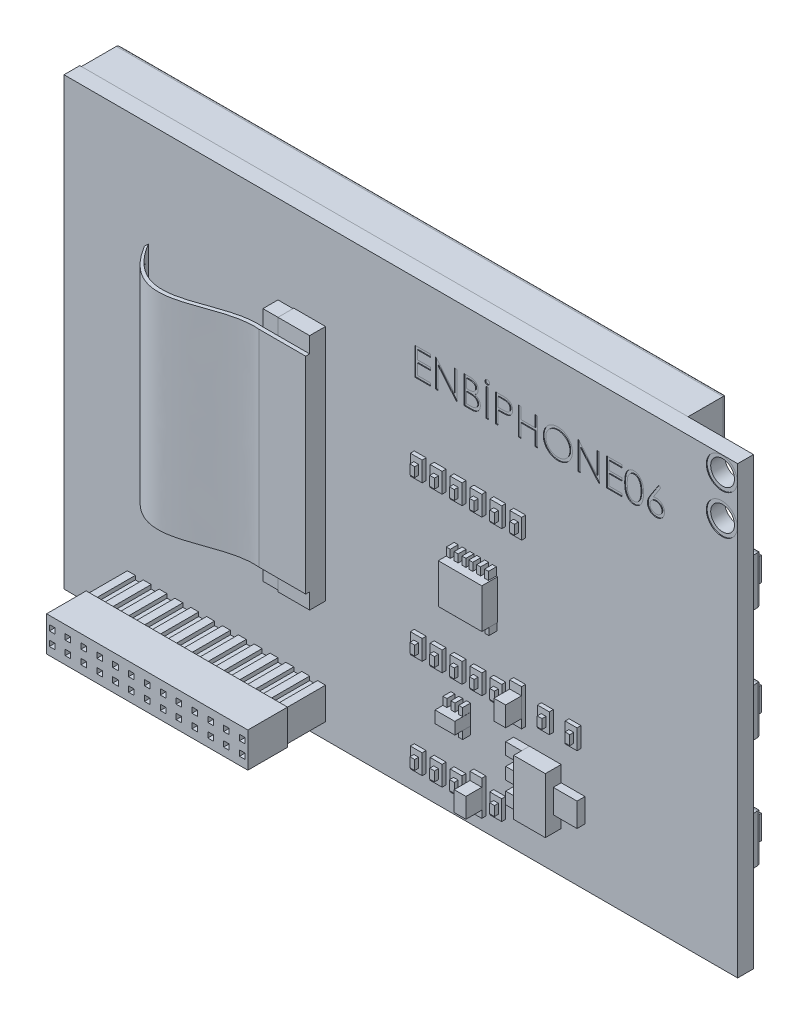
from build123d import *

# Parameters (mm, degrees)
SKETCH1_W            = 85.01
SKETCH1_H            = 56.21
BOSS_EXTRUDE1_DEPTH  = 2
SKETCH2_R            = 1.5
CUT_EXTRUDE1_DEPTH   = 2
SKETCH4_R            = 1.95
SKETCH4_R_2          = 1.5
CUT_EXTRUDE7_DEPTH   = 0.1
SKETCH5_R            = 1.95
SKETCH5_R_2          = 1.5
CUT_EXTRUDE8_DEPTH   = 0.1
SKETCH6_W            = 76.55
SKETCH6_H            = 53.88
BOSS_EXTRUDE2_DEPTH  = 5
SKETCH7_W            = 73.65
SKETCH7_H            = 50.98
CUT_EXTRUDE9_DEPTH   = 0.1
FILLET1_R            = 0.5
SKETCH8_W            = 3
SKETCH8_H            = 6
BOSS_EXTRUDE3_DEPTH  = 2
FILLET2_R            = 0.5
SKETCH9_W            = 1
SKETCH9_H            = 3
BOSS_EXTRUDE4_DEPTH  = 1
BOSS_EXTRUDE5_DEPTH  = 5
SKETCH11_W           = 25.4
SKETCH11_H           = 4.4
SKETCH11_W_2         = 0.7
SKETCH11_H_2         = 0.7
BOSS_EXTRUDE6_DEPTH  = 5
SKETCH13_W           = 1.5
SKETCH13_H           = 2.5
SKETCH13_H_2         = 4.4
SKETCH13_H_3         = 4.616877195
BOSS_EXTRUDE7_DEPTH  = 0.5
SKETCH16_W           = 0.6
SKETCH16_H           = 1.2
BOSS_EXTRUDE8_DEPTH  = 0.5
SKETCH17_W           = 1.48
SKETCH17_H           = 2.5
BOSS_EXTRUDE9_DEPTH  = 2
SKETCH19_W           = 4
SKETCH19_H           = 7
SKETCH19_W_2         = 2.5
SKETCH19_H_2         = 1.5
SKETCH19_W_3         = 5.5
SKETCH19_H_3         = 5
BOSS_EXTRUDE10_DEPTH = 2
SKETCH21_W           = 0.5
SKETCH21_H           = 1
SKETCH21_W_2         = 3
SKETCH21_H_2         = 3
SKETCH21_W_3         = 2
SKETCH21_H_3         = 1.5
BOSS_EXTRUDE12_DEPTH = 1
SKETCH22_W           = 4
SKETCH22_H           = 30
BOSS_EXTRUDE13_DEPTH = 2
SKETCH23_W           = 2
SKETCH23_H           = 29.8
BOSS_EXTRUDE14_DEPTH = 1.9
SKETCH25_W           = 5.9
SKETCH25_H           = 26
BOSS_EXTRUDE15_DEPTH = 0.5
BOSS_EXTRUDE16_DEPTH = 26
SKETCH28_W           = 0.314102564
SKETCH28_H           = 3.5
CUT_EXTRUDE10_DEPTH  = 0.1


with BuildPart() as part:
    # Sketch1 → Boss-Extrude1 (new body)
    with BuildSketch(Plane.XY):
        with Locations((42.505, 28.105)):
            Rectangle(SKETCH1_W, SKETCH1_H)
    extrude(amount=BOSS_EXTRUDE1_DEPTH)

    # Sketch2 → Cut-Extrude1 (cut)
    with BuildSketch(Plane.XY.offset(2)):
        with Locations((83.01, 54.21)):
            Circle(SKETCH2_R)
        with Locations((83.01, 49.21)):
            Circle(SKETCH2_R)
    extrude(amount=-CUT_EXTRUDE1_DEPTH, mode=Mode.SUBTRACT)

    # Sketch4 → Cut-Extrude7 (cut)
    with BuildSketch(Plane.XY.offset(2)):
        with Locations((83.01, 54.21)):
            Circle(SKETCH4_R)
        with Locations((83.01, 54.21)):
            Circle(SKETCH4_R_2, mode=Mode.SUBTRACT)
        with Locations((83.01, 49.21)):
            Circle(SKETCH4_R)
        with Locations((83.01, 49.21)):
            Circle(SKETCH4_R_2, mode=Mode.SUBTRACT)
    extrude(amount=-CUT_EXTRUDE7_DEPTH, mode=Mode.SUBTRACT)

    # Sketch5 → Cut-Extrude8 (cut)
    with BuildSketch(Plane(origin=(0, 0, 0), x_dir=(-1, 0, 0), z_dir=(0, 0, -1))):
        with Locations((-83.01, 54.21)):
            Circle(SKETCH5_R)
        with Locations((-83.01, 54.21)):
            Circle(SKETCH5_R_2, mode=Mode.SUBTRACT)
        with Locations((-83.01, 49.21)):
            Circle(SKETCH5_R)
        with Locations((-83.01, 49.21)):
            Circle(SKETCH5_R_2, mode=Mode.SUBTRACT)
    extrude(amount=-CUT_EXTRUDE8_DEPTH, mode=Mode.SUBTRACT)

    # Sketch6 → Boss-Extrude2 (add)
    with BuildSketch(Plane(origin=(0, 0, 0), x_dir=(-1, 0, 0), z_dir=(0, 0, -1))):
        with Locations((-38.375, 29.17)):
            Rectangle(SKETCH6_W, SKETCH6_H)
    extrude(amount=BOSS_EXTRUDE2_DEPTH)

    # Sketch7 → Cut-Extrude9 (cut)
    with BuildSketch(Plane(origin=(0, 0, -5), x_dir=(-1, 0, 0), z_dir=(0, 0, -1))):
        with Locations((-38.325, 29.22)):
            Rectangle(SKETCH7_W, SKETCH7_H)
    extrude(amount=-CUT_EXTRUDE9_DEPTH, mode=Mode.SUBTRACT)

    # Fillet1
    fillet1_edges = [part.edges().sort_by_distance(p)[0] for p in [
        (38.375, 56.11, -5),
        (76.65, 29.17, -5),
        (38.375, 2.23, -5),
        (0.1, 29.17, -5),
    ]]
    fillet(fillet1_edges, radius=FILLET1_R)

    # Sketch8 → Boss-Extrude3 (add)
    with BuildSketch(Plane(origin=(0, 0, 0), x_dir=(-1, 0, 0), z_dir=(0, 0, -1))):
        with Locations((-82.51, 13)):
            Rectangle(SKETCH8_W, SKETCH8_H)
        with Locations((-82.51, 27)):
            Rectangle(SKETCH8_W, SKETCH8_H)
        with Locations((-82.51, 41.21)):
            Rectangle(SKETCH8_W, SKETCH8_H)
    extrude(amount=BOSS_EXTRUDE3_DEPTH)

    # Fillet2
    fillet2_edges = [part.edges().sort_by_distance(p)[0] for p in [
        (81.01, 27, -2),
        (82.51, 30, -2),
        (84.01, 27, -2),
        (82.51, 24, -2),
        (82.51, 44.21, -2),
        (84.01, 41.21, -2),
        (82.51, 38.21, -2),
        (81.01, 41.21, -2),
        (84.01, 13, -2),
        (82.51, 10, -2),
        (81.01, 13, -2),
        (82.51, 16, -2),
    ]]
    fillet(fillet2_edges, radius=FILLET2_R)

    # Sketch9 → Boss-Extrude4 (add)
    with BuildSketch(Plane(origin=(0, 0, -2), x_dir=(-1, 0, 0), z_dir=(0, 0, -1))):
        with Locations((-82.51, 41.21)):
            Rectangle(SKETCH9_W, SKETCH9_H)
        with Locations((-82.51, 27)):
            Rectangle(SKETCH9_W, SKETCH9_H)
        with Locations((-82.51, 13)):
            Rectangle(SKETCH9_W, SKETCH9_H)
    extrude(amount=BOSS_EXTRUDE4_DEPTH)

    # Sketch10 → Boss-Extrude5 (add)
    with BuildSketch(Plane.XY.offset(2)):
        Polygon((8, 2), (8, 6), (9, 6), (9, 5.5), (10, 5.5), (10, 6), (11, 6), (11, 5.5), (12, 5.5), (12, 6), (13, 6), (13, 5.5), (14, 5.5), (14, 6), (15, 6), (15, 5.5), (16, 5.5), (16, 6), (17, 6), (17, 5.5), (18, 5.5), (18, 6), (19, 6), (19, 5.5), (20, 5.5), (20, 6), (21, 6), (21, 5.5), (22, 5.5), (22, 6), (23, 6), (23, 5.5), (24, 5.5), (24, 6), (25, 6), (25, 5.5), (26, 5.5), (26, 6), (27, 6), (27, 5.5), (28, 5.5), (28, 6), (29, 6), (29, 5.5), (30, 5.5), (30, 6), (31, 6), (31, 5.5), (32, 5.5), (32, 6), (33, 6), (33, 2), (32, 2), (32, 2.5), (31, 2.5), (31, 2), (30, 2), (30, 2.5), (29, 2.5), (29, 2), (28, 2), (28, 2.5), (27, 2.5), (27, 2), (26, 2), (26, 2.5), (25, 2.5), (25, 2), (24, 2), (24, 2.5), (23, 2.5), (23, 2), (22, 2), (22, 2.5), (21, 2.5), (21, 2), (20, 2), (20, 2.5), (19, 2.5), (19, 2), (18, 2), (18, 2.5), (17, 2.5), (17, 2), (16, 2), (16, 2.5), (15, 2.5), (15, 2), (14, 2), (14, 2.5), (13, 2.5), (13, 2), (12, 2), (12, 2.5), (11, 2.5), (11, 2), (10, 2), (10, 2.5), (9, 2.5), (9, 2), align=None)
    extrude(amount=BOSS_EXTRUDE5_DEPTH)

    # Sketch11 → Boss-Extrude6 (add)
    with BuildSketch(Plane.XY.offset(7)):
        with Locations((20.5, 4)):
            Rectangle(SKETCH11_W, SKETCH11_H)
        with Locations((8.5, 4.85)):
            Rectangle(SKETCH11_W_2, SKETCH11_H_2, mode=Mode.SUBTRACT)
        with Locations((10.5, 4.85)):
            Rectangle(SKETCH11_W_2, SKETCH11_H_2, mode=Mode.SUBTRACT)
        with Locations((32.5, 3.15)):
            Rectangle(SKETCH11_W_2, SKETCH11_H_2, mode=Mode.SUBTRACT)
        with Locations((12.5, 4.85)):
            Rectangle(SKETCH11_W_2, SKETCH11_H_2, mode=Mode.SUBTRACT)
        with Locations((14.5, 4.85)):
            Rectangle(SKETCH11_W_2, SKETCH11_H_2, mode=Mode.SUBTRACT)
        with Locations((16.5, 4.85)):
            Rectangle(SKETCH11_W_2, SKETCH11_H_2, mode=Mode.SUBTRACT)
        with Locations((18.5, 4.85)):
            Rectangle(SKETCH11_W_2, SKETCH11_H_2, mode=Mode.SUBTRACT)
        with Locations((30.5, 3.15)):
            Rectangle(SKETCH11_W_2, SKETCH11_H_2, mode=Mode.SUBTRACT)
        with Locations((20.5, 4.85)):
            Rectangle(SKETCH11_W_2, SKETCH11_H_2, mode=Mode.SUBTRACT)
        with Locations((22.5, 4.85)):
            Rectangle(SKETCH11_W_2, SKETCH11_H_2, mode=Mode.SUBTRACT)
        with Locations((24.5, 4.85)):
            Rectangle(SKETCH11_W_2, SKETCH11_H_2, mode=Mode.SUBTRACT)
        with Locations((26.5, 4.85)):
            Rectangle(SKETCH11_W_2, SKETCH11_H_2, mode=Mode.SUBTRACT)
        with Locations((28.5, 3.15)):
            Rectangle(SKETCH11_W_2, SKETCH11_H_2, mode=Mode.SUBTRACT)
        with Locations((28.5, 4.85)):
            Rectangle(SKETCH11_W_2, SKETCH11_H_2, mode=Mode.SUBTRACT)
        with Locations((30.5, 4.85)):
            Rectangle(SKETCH11_W_2, SKETCH11_H_2, mode=Mode.SUBTRACT)
        with Locations((32.5, 4.85)):
            Rectangle(SKETCH11_W_2, SKETCH11_H_2, mode=Mode.SUBTRACT)
        with Locations((26.5, 3.15)):
            Rectangle(SKETCH11_W_2, SKETCH11_H_2, mode=Mode.SUBTRACT)
        with Locations((24.5, 3.15)):
            Rectangle(SKETCH11_W_2, SKETCH11_H_2, mode=Mode.SUBTRACT)
        with Locations((22.5, 3.15)):
            Rectangle(SKETCH11_W_2, SKETCH11_H_2, mode=Mode.SUBTRACT)
        with Locations((20.5, 3.15)):
            Rectangle(SKETCH11_W_2, SKETCH11_H_2, mode=Mode.SUBTRACT)
        with Locations((18.5, 3.15)):
            Rectangle(SKETCH11_W_2, SKETCH11_H_2, mode=Mode.SUBTRACT)
        with Locations((16.5, 3.15)):
            Rectangle(SKETCH11_W_2, SKETCH11_H_2, mode=Mode.SUBTRACT)
        with Locations((14.5, 3.15)):
            Rectangle(SKETCH11_W_2, SKETCH11_H_2, mode=Mode.SUBTRACT)
        with Locations((12.5, 3.15)):
            Rectangle(SKETCH11_W_2, SKETCH11_H_2, mode=Mode.SUBTRACT)
        with Locations((10.5, 3.15)):
            Rectangle(SKETCH11_W_2, SKETCH11_H_2, mode=Mode.SUBTRACT)
        with Locations((8.5, 3.15)):
            Rectangle(SKETCH11_W_2, SKETCH11_H_2, mode=Mode.SUBTRACT)
    extrude(amount=BOSS_EXTRUDE6_DEPTH)

    # Sketch13 → Boss-Extrude7 (add)
    with BuildSketch(Plane.XY.offset(2)):
        with Locations((44.95, 3.95)):
            Rectangle(SKETCH13_W, SKETCH13_H)
        with Locations((52.477548998, 35.967092454)):
            Rectangle(SKETCH13_W, SKETCH13_H)
        with Locations((47.463774499, 3.95)):
            Rectangle(SKETCH13_W, SKETCH13_H)
        with Locations((49.977548998, 3.95)):
            Rectangle(SKETCH13_W, SKETCH13_H)
        with Locations((52.477548998, 4)):
            Rectangle(SKETCH13_W, SKETCH13_H_2)
        with Locations((54.977548998, 3.95)):
            Rectangle(SKETCH13_W, SKETCH13_H)
        with Locations((49.977548998, 16.45)):
            Rectangle(SKETCH13_W, SKETCH13_H)
        with Locations((47.463774499, 16.45)):
            Rectangle(SKETCH13_W, SKETCH13_H)
        with Locations((44.95, 16.45)):
            Rectangle(SKETCH13_W, SKETCH13_H)
        with Locations((52.477548998, 16.45)):
            Rectangle(SKETCH13_W, SKETCH13_H)
        with Locations((54.991323497, 16.45)):
            Rectangle(SKETCH13_W, SKETCH13_H)
        with Locations((57.491323497, 16.391561403)):
            Rectangle(SKETCH13_W, SKETCH13_H_3)
        with Locations((60.991323497, 16.45)):
            Rectangle(SKETCH13_W, SKETCH13_H)
        with Locations((64.491323497, 16.45)):
            Rectangle(SKETCH13_W, SKETCH13_H)
        with Locations((54.991323497, 35.967092454)):
            Rectangle(SKETCH13_W, SKETCH13_H)
        with Locations((47.463774499, 35.967092454)):
            Rectangle(SKETCH13_W, SKETCH13_H)
        with Locations((49.977548998, 35.967092454)):
            Rectangle(SKETCH13_W, SKETCH13_H)
        with Locations((44.95, 35.95)):
            Rectangle(SKETCH13_W, SKETCH13_H)
        with Locations((57.505097996, 35.967092454)):
            Rectangle(SKETCH13_W, SKETCH13_H)
    extrude(amount=BOSS_EXTRUDE7_DEPTH)

    # Sketch16 → Boss-Extrude8 (add)
    with BuildSketch(Plane.XY.offset(2.5)):
        with Locations((44.95, 3.9)):
            Rectangle(SKETCH16_W, SKETCH16_H)
        with Locations((47.45, 3.9)):
            Rectangle(SKETCH16_W, SKETCH16_H)
        with Locations((49.95, 3.9)):
            Rectangle(SKETCH16_W, SKETCH16_H)
        with Locations((55.020165357, 16.4)):
            Rectangle(SKETCH16_W, SKETCH16_H)
        with Locations((44.95, 16.4)):
            Rectangle(SKETCH16_W, SKETCH16_H)
        with Locations((49.95, 16.4)):
            Rectangle(SKETCH16_W, SKETCH16_H)
        with Locations((55.020165357, 3.9)):
            Rectangle(SKETCH16_W, SKETCH16_H)
        with Locations((47.45, 16.4)):
            Rectangle(SKETCH16_W, SKETCH16_H)
        with Locations((52.45, 16.4)):
            Rectangle(SKETCH16_W, SKETCH16_H)
        with Locations((61.020165357, 16.4)):
            Rectangle(SKETCH16_W, SKETCH16_H)
        with Locations((64.520165357, 16.4)):
            Rectangle(SKETCH16_W, SKETCH16_H)
        with Locations((55.020165357, 35.9)):
            Rectangle(SKETCH16_W, SKETCH16_H)
        with Locations((52.45, 35.9)):
            Rectangle(SKETCH16_W, SKETCH16_H)
        with Locations((44.95, 35.9)):
            Rectangle(SKETCH16_W, SKETCH16_H)
        with Locations((49.95, 35.9)):
            Rectangle(SKETCH16_W, SKETCH16_H)
        with Locations((47.45, 35.9)):
            Rectangle(SKETCH16_W, SKETCH16_H)
        with Locations((57.533939856, 35.9)):
            Rectangle(SKETCH16_W, SKETCH16_H)
    extrude(amount=BOSS_EXTRUDE8_DEPTH)

    # Sketch17 → Boss-Extrude9 (add)
    with BuildSketch(Plane.XY.offset(2.5)):
        with Locations((52.477548998, 3.95)):
            Rectangle(SKETCH17_W, SKETCH17_H)
        with Locations((57.491323497, 16.45)):
            Rectangle(SKETCH17_W, SKETCH17_H)
    extrude(amount=BOSS_EXTRUDE9_DEPTH)

    # Sketch19 → Boss-Extrude10 (add)
    with BuildSketch(Plane.XY.offset(2)):
        with Locations((60.741323497, 8.7)):
            Rectangle(SKETCH19_W, SKETCH19_H)
        with Locations((50.06634195, 11.45)):
            Rectangle(SKETCH19_W_2, SKETCH19_H_2)
        with Locations((51.977548998, 26.217092454)):
            Rectangle(SKETCH19_W_3, SKETCH19_H_3)
    extrude(amount=BOSS_EXTRUDE10_DEPTH)

    # Sketch21 → Boss-Extrude12 (add)
    with BuildSketch(Plane.XY.offset(2)):
        with Locations((49.07634195, 12.7)):
            Rectangle(SKETCH21_W, SKETCH21_H)
        with Locations((50.07634195, 12.7)):
            Rectangle(SKETCH21_W, SKETCH21_H)
        with Locations((51.05634195, 12.7)):
            Rectangle(SKETCH21_W, SKETCH21_H)
        with Locations((51.05634195, 10.2)):
            Rectangle(SKETCH21_W, SKETCH21_H)
        with Locations((50.07634195, 10.2)):
            Rectangle(SKETCH21_W, SKETCH21_H)
        with Locations((49.07634195, 10.2)):
            Rectangle(SKETCH21_W, SKETCH21_H)
        with Locations((50.487548998, 29.217092454)):
            Rectangle(SKETCH21_W, SKETCH21_H)
        with Locations((49.487548998, 29.217092454)):
            Rectangle(SKETCH21_W, SKETCH21_H)
        with Locations((51.467548998, 29.217092454)):
            Rectangle(SKETCH21_W, SKETCH21_H)
        with Locations((53.33135448, 29.217092454)):
            Rectangle(SKETCH21_W, SKETCH21_H)
        with Locations((52.33135448, 29.217092454)):
            Rectangle(SKETCH21_W, SKETCH21_H)
        with Locations((54.31135448, 29.217092454)):
            Rectangle(SKETCH21_W, SKETCH21_H)
        with Locations((51.521343836, 23.214974242)):
            Rectangle(SKETCH21_W, SKETCH21_H)
        with Locations((52.385149318, 23.214974242)):
            Rectangle(SKETCH21_W, SKETCH21_H)
        with Locations((53.385149318, 23.214974242)):
            Rectangle(SKETCH21_W, SKETCH21_H)
        with Locations((54.365149318, 23.214974242)):
            Rectangle(SKETCH21_W, SKETCH21_H)
        with Locations((50.541343836, 23.214974242)):
            Rectangle(SKETCH21_W, SKETCH21_H)
        with Locations((49.541343836, 23.214974242)):
            Rectangle(SKETCH21_W, SKETCH21_H)
        with Locations((64.241323497, 8.7)):
            Rectangle(SKETCH21_W_2, SKETCH21_H_2)
        with Locations((57.741323497, 11.44)):
            Rectangle(SKETCH21_W_3, SKETCH21_H_3)
        with Locations((57.741323497, 8.74)):
            Rectangle(SKETCH21_W_3, SKETCH21_H_3)
        with Locations((57.741323497, 6.04)):
            Rectangle(SKETCH21_W_3, SKETCH21_H_3)
    extrude(amount=BOSS_EXTRUDE12_DEPTH)

    # Sketch22 → Boss-Extrude13 (add)
    with BuildSketch(Plane.XY.offset(2)):
        with Locations((31, 30.2)):
            Rectangle(SKETCH22_W, SKETCH22_H)
    extrude(amount=BOSS_EXTRUDE13_DEPTH)

    # Sketch23 → Boss-Extrude14 (add)
    with BuildSketch(Plane.XY.offset(2)):
        with Locations((28, 30.2)):
            Rectangle(SKETCH23_W, SKETCH23_H)
    extrude(amount=BOSS_EXTRUDE14_DEPTH)

    # Sketch25 → Boss-Extrude15 (add)
    with BuildSketch(Plane.XY.offset(4)):
        with Locations((30.05, 30.2)):
            Rectangle(SKETCH25_W, SKETCH25_H)
    extrude(amount=BOSS_EXTRUDE15_DEPTH)

    # Sketch26 → Boss-Extrude16 (add)
    with BuildSketch(Plane(origin=(0, 43.2, 0), x_dir=(1, 0, 0), z_dir=(0, 1, 0))):
        with BuildLine():
            Line((27.1, -4.5), (27.1, -4))
            add(Edge.make_bspline(
                [(27.1, -4), (21.203971865, -3.448625786), (15.858377482, -10.525644499), (10.802416979, -2.164049527)],
                knots=[0, 0, 0, 0, 1, 1, 1, 1], degree=3))
            Line((10.802416979, -2.164049527), (10.802416979, -2.664049527))
            add(Edge.make_bspline(
                [(27.1, -4.5), (21.203971865, -3.948625786), (15.858377482, -11.025644499), (10.802416979, -2.664049527)],
                knots=[0, 0, 0, 0, 1, 1, 1, 1], degree=3))
        make_face()
    extrude(amount=-BOSS_EXTRUDE16_DEPTH)

    # Sketch28 → Cut-Extrude10 (cut)
    with BuildSketch(Plane.XY.offset(2)):
        Polygon((44.281025042, 48.793626853), (46.255384016, 48.793626853), (46.255384016, 48.434652494), (44.595127606, 48.434652494), (44.595127606, 47.357729418), (46.255384016, 47.357729418), (46.255384016, 46.998755059), (44.595127606, 46.998755059), (44.595127606, 45.652601212), (46.255384016, 45.652601212), (46.255384016, 45.293626853), (44.281025042, 45.293626853), align=None)
        Polygon((46.883589144, 45.293626853), (46.883589144, 48.793626853), (46.949494593, 48.793626853), (49.261794272, 46.038919321), (49.261794272, 48.793626853), (49.575896837, 48.793626853), (49.575896837, 45.293626853), (49.504382413, 45.293626853), (47.197691708, 48.042024289), (47.197691708, 45.293626853), align=None)
        with BuildLine():
            Line((50.473332734, 48.793626853), (51.156225362, 48.793626853))
            add(Edge.make_bspline(
                [(51.156225362, 48.793626853), (51.18965384, 48.793451103), (51.254446551, 48.793110455), (51.348665993, 48.787827324), (51.436914803, 48.780623654), (51.519218576, 48.769193561), (51.595539278, 48.755401784), (51.666106915, 48.738699968), (51.730697087, 48.718673354), (51.807809824, 48.686827073), (51.895730485, 48.639503905), (51.990928877, 48.56957534), (52.072333117, 48.484042877), (52.142519434, 48.387560221), (52.198320554, 48.281424449), (52.238689851, 48.168165261), (52.264247726, 48.049243519), (52.26687616, 47.967600341), (52.268204529, 47.926339193)],
                knots=[0, 0, 0, 0, 0.00010027, 0.000194349, 0.000283026, 0.000365821, 0.000443519, 0.000515622, 0.000583254, 0.00064614, 0.000765662, 0.000881909, 0.000998927, 0.001118415, 0.001238844, 0.00135727, 0.001478274, 0.001601912, 0.001601912, 0.001601912, 0.001601912], degree=3))
            add(Edge.make_bspline(
                [(52.268204529, 47.926339193), (52.26711131, 47.887686638), (52.264963033, 47.81173072), (52.244420274, 47.700636611), (52.212259605, 47.594885392), (52.167554356, 47.494863007), (52.10945236, 47.402829394), (52.040594041, 47.318042128), (51.957517239, 47.244091071), (51.895273999, 47.202748168), (51.863657253, 47.181747847)],
                knots=[0, 0, 0, 0, 0.000115857, 0.00022767, 0.000337672, 0.000446877, 0.000555233, 0.000663318, 0.000773539, 0.000887324, 0.000887324, 0.000887324, 0.000887324], degree=3))
            add(Edge.make_bspline(
                [(51.863657253, 47.181747847), (51.903417681, 47.166482848), (51.979489228, 47.137277124), (52.084175241, 47.08564166), (52.174370086, 47.029479549), (52.250767232, 46.968147699), (52.316104886, 46.902038888), (52.373157828, 46.830183774), (52.421839202, 46.751645016), (52.463552126, 46.667241481), (52.496100882, 46.577835013), (52.520476786, 46.484264236), (52.534444235, 46.386864681), (52.536431877, 46.320579302), (52.537435298, 46.287116437)],
                knots=[0, 0, 0, 0, 0.000127722, 0.000244363, 0.000349599, 0.000445847, 0.000537565, 0.000627901, 0.000720503, 0.000814257, 0.000909859, 0.001005428, 0.001103887, 0.001204268, 0.001204268, 0.001204268, 0.001204268], degree=3))
            add(Edge.make_bspline(
                [(52.537435298, 46.287116437), (52.536458452, 46.252949565), (52.53453648, 46.185725287), (52.520356508, 46.086970152), (52.496347401, 45.992595205), (52.463276255, 45.901990023), (52.42011394, 45.815329888), (52.367585976, 45.732516624), (52.304954412, 45.654382294), (52.234891543, 45.580058671), (52.155629398, 45.513230883), (52.070113643, 45.453715176), (51.977267323, 45.404769114), (51.878615329, 45.363653093), (51.773051013, 45.332245894), (51.661048406, 45.310273321), (51.542704104, 45.295468284), (51.461494353, 45.294251079), (51.419847157, 45.293626853)],
                knots=[0, 0, 0, 0, 0.000102481, 0.000201635, 0.000298562, 0.000394165, 0.000490425, 0.000588455, 0.000687769, 0.000790423, 0.000894381, 0.000998232, 0.001102369, 0.001208616, 0.001318415, 0.001432129, 0.001550749, 0.00167562, 0.00167562, 0.00167562, 0.00167562], degree=3))
            Line((51.419847157, 45.293626853), (50.473332734, 45.293626853))
            Line((50.473332734, 45.293626853), (50.473332734, 48.793626853))
        make_face()
        with BuildLine():
            Line((50.787435298, 48.434652494), (50.787435298, 47.312857623))
            Line((50.787435298, 47.312857623), (50.998472958, 47.312857623))
            add(Edge.make_bspline(
                [(50.998472958, 47.312857623), (51.029321754, 47.313257546), (51.088927913, 47.314030278), (51.175247809, 47.316243795), (51.255372828, 47.322441839), (51.329164661, 47.328638101), (51.396507105, 47.338712689), (51.457250966, 47.350704812), (51.512349563, 47.363387717), (51.575889109, 47.384957204), (51.647962057, 47.416834879), (51.724795161, 47.466306715), (51.792529631, 47.525231068), (51.849726819, 47.59322203), (51.896538289, 47.668088216), (51.929052004, 47.748635096), (51.951099288, 47.832855228), (51.95309082, 47.890673481), (51.954101965, 47.920029097)],
                knots=[0, 0, 0, 0, 9.2559e-05, 0.000178842, 0.000258967, 0.000333616, 0.000400942, 0.000463093, 0.000519379, 0.000570374, 0.000664201, 0.000755025, 0.000843472, 0.000932526, 0.001020669, 0.001107124, 0.001192318, 0.001280185, 0.001280185, 0.001280185, 0.001280185], degree=3))
            add(Edge.make_bspline(
                [(51.954101965, 47.920029097), (51.953575785, 47.939454869), (51.952543625, 47.977560641), (51.944090322, 48.033109995), (51.929722748, 48.085353747), (51.911268454, 48.135007858), (51.885479766, 48.180519708), (51.855116302, 48.223462904), (51.818430612, 48.262375022), (51.776673299, 48.29874452), (51.728664677, 48.330989048), (51.674433385, 48.359229811), (51.613245708, 48.381970588), (51.546132853, 48.40188674), (51.472061765, 48.415875034), (51.391887212, 48.427528422), (51.304952493, 48.433461164), (51.24480739, 48.434246527), (51.213717349, 48.434652494)],
                knots=[0, 0, 0, 0, 5.8261e-05, 0.000114285, 0.000168029, 0.000220632, 0.000272728, 0.000324483, 0.000378062, 0.000432741, 0.000490301, 0.000551137, 0.000615721, 0.000685833, 0.000760908, 0.00084162, 0.000928788, 0.00102206, 0.00102206, 0.00102206, 0.00102206], degree=3))
            Line((51.213717349, 48.434652494), (50.787435298, 48.434652494))
        make_face(mode=Mode.SUBTRACT)
        with BuildLine():
            Line((50.787435298, 46.953883264), (50.787435298, 45.652601212))
            Line((50.787435298, 45.652601212), (51.234751003, 45.652601212))
            add(Edge.make_bspline(
                [(51.234751003, 45.652601212), (51.266769929, 45.65298496), (51.328482188, 45.653724582), (51.417583418, 45.656139137), (51.500166522, 45.661631413), (51.575854657, 45.670277262), (51.64546511, 45.679655711), (51.708162813, 45.692266992), (51.764456006, 45.706715953), (51.829730314, 45.729050125), (51.903233822, 45.763746596), (51.982444679, 45.816060822), (52.052870897, 45.87838413), (52.112676156, 45.950515044), (52.161689145, 46.028946371), (52.1973446, 46.112091721), (52.219335457, 46.198577249), (52.221997626, 46.257543961), (52.223332734, 46.287116437)],
                knots=[0, 0, 0, 0, 9.6064e-05, 0.000185151, 0.000267373, 0.000344257, 0.000413665, 0.000478015, 0.000536005, 0.000587888, 0.000684801, 0.000778918, 0.000871787, 0.000965866, 0.001059062, 0.00114827, 0.001236355, 0.001324974, 0.001324974, 0.001324974, 0.001324974], degree=3))
            add(Edge.make_bspline(
                [(52.223332734, 46.287116437), (52.22305663, 46.305609777), (52.222508875, 46.342298159), (52.21424826, 46.396213978), (52.20223439, 46.448439852), (52.186702956, 46.499117592), (52.164083489, 46.547330968), (52.137676944, 46.594033528), (52.106715542, 46.639287007), (52.058471376, 46.696499261), (51.988299392, 46.762416274), (51.888592616, 46.826953776), (51.775220318, 46.879001583), (51.692992825, 46.901101059), (51.650516228, 46.912517078)],
                knots=[0, 0, 0, 0, 5.5429e-05, 0.000109963, 0.000163198, 0.000216191, 0.000268588, 0.000322593, 0.000377046, 0.000432793, 0.000546889, 0.000664343, 0.000787646, 0.000919405, 0.000919405, 0.000919405, 0.000919405], degree=3))
            add(Edge.make_bspline(
                [(51.650516228, 46.912517078), (51.633487132, 46.915972162), (51.596564539, 46.923463496), (51.536356959, 46.9313712), (51.46762109, 46.93841626), (51.390198213, 46.943627417), (51.303990372, 46.949013961), (51.208813453, 46.951108782), (51.105056138, 46.953608042), (51.033063766, 46.953789176), (50.995668471, 46.953883264)],
                knots=[0, 0, 0, 0, 5.2115e-05, 0.000112995, 0.000182062, 0.000259389, 0.000345767, 0.00044116, 0.000544948, 0.000657129, 0.000657129, 0.000657129, 0.000657129], degree=3))
            Line((50.995668471, 46.953883264), (50.787435298, 46.953883264))
        make_face(mode=Mode.SUBTRACT)
        with Locations((53.412435298, 47.043626853)):
            Rectangle(SKETCH28_W, SKETCH28_H)
        with BuildLine():
            add(Edge.make_bspline(
                [(53.412435298, 49.601319161), (53.431916304, 49.600144348), (53.470106538, 49.597841263), (53.525586444, 49.582471089), (53.575163638, 49.553815021), (53.619931675, 49.517148871), (53.656597825, 49.472380835), (53.685253893, 49.422803641), (53.700624067, 49.367323734), (53.702927151, 49.3291335), (53.704101965, 49.309652494)],
                knots=[0, 0, 0, 0, 5.8463e-05, 0.000114609, 0.000170791, 0.000229052, 0.000287312, 0.000343494, 0.000399641, 0.000458104, 0.000458104, 0.000458104, 0.000458104], degree=3))
            add(Edge.make_bspline(
                [(53.704101965, 49.309652494), (53.702965528, 49.290157803), (53.700750776, 49.252165425), (53.684913016, 49.1968904), (53.656854091, 49.14700403), (53.619863131, 49.102247606), (53.575394764, 49.065281557), (53.525244636, 49.037894454), (53.470266111, 49.021192917), (53.431948036, 49.019067934), (53.412435298, 49.017985828)],
                knots=[0, 0, 0, 0, 5.8463e-05, 0.000113936, 0.000170731, 0.000228992, 0.000287252, 0.000343096, 0.000399439, 0.000457902, 0.000457902, 0.000457902, 0.000457902], degree=3))
            add(Edge.make_bspline(
                [(53.412435298, 49.017985828), (53.392908501, 49.019028758), (53.354787078, 49.02106483), (53.300013719, 49.038237094), (53.249558065, 49.065024111), (53.205098347, 49.102315543), (53.167806914, 49.146775261), (53.141019898, 49.197230915), (53.123847633, 49.252004274), (53.121811561, 49.290125697), (53.120768631, 49.309652494)],
                knots=[0, 0, 0, 0, 5.8463e-05, 0.000114135, 0.000170596, 0.000228856, 0.000287117, 0.000343578, 0.00039925, 0.000457713, 0.000457713, 0.000457713, 0.000457713], degree=3))
            add(Edge.make_bspline(
                [(53.120768631, 49.309652494), (53.121850738, 49.329165232), (53.12397572, 49.367483307), (53.140677258, 49.422461832), (53.168064361, 49.472611961), (53.20503041, 49.517080328), (53.249786833, 49.554071287), (53.299673203, 49.582130213), (53.354948229, 49.597967972), (53.392940607, 49.600182725), (53.412435298, 49.601319161)],
                knots=[0, 0, 0, 0, 5.8463e-05, 0.000114806, 0.00017065, 0.000228911, 0.000287171, 0.000343966, 0.000399439, 0.000457902, 0.000457902, 0.000457902, 0.000457902], degree=3))
        make_face()
        with BuildLine():
            Line((54.466922478, 48.793626853), (55.153320715, 48.793626853))
            add(Edge.make_bspline(
                [(55.153320715, 48.793626853), (55.200531621, 48.793574957), (55.290989814, 48.793475522), (55.420704869, 48.790460776), (55.538514601, 48.786434084), (55.644164982, 48.780852191), (55.73798108, 48.7742556), (55.81953838, 48.765003561), (55.889477936, 48.755343265), (55.931384385, 48.745521859), (55.950496195, 48.741042719)],
                knots=[0, 0, 0, 0, 0.000141628, 0.000271366, 0.00038923, 0.000495248, 0.00058876, 0.000671296, 0.000741499, 0.00080036, 0.00080036, 0.00080036, 0.00080036], degree=3))
            add(Edge.make_bspline(
                [(55.950496195, 48.741042719), (55.974689729, 48.734420769), (56.022506706, 48.721332907), (56.09140775, 48.695119184), (56.156961595, 48.664037019), (56.219393154, 48.628613079), (56.277935237, 48.587327515), (56.333461278, 48.541853897), (56.385481258, 48.491142328), (56.43370265, 48.435761588), (56.477987447, 48.376641379), (56.51611713, 48.312899149), (56.548044357, 48.245607845), (56.575427629, 48.174814274), (56.595136083, 48.099923951), (56.609982983, 48.021457238), (56.61940661, 47.939422548), (56.620309172, 47.88336268), (56.620768631, 47.85482477)],
                knots=[0, 0, 0, 0, 7.5216e-05, 0.00014866, 0.000220794, 0.000292713, 0.000363707, 0.000435434, 0.000507823, 0.000581364, 0.000655543, 0.000729131, 0.000803767, 0.000878771, 0.000956497, 0.001035702, 0.001118238, 0.001203821, 0.001203821, 0.001203821, 0.001203821], degree=3))
            add(Edge.make_bspline(
                [(56.620768631, 47.85482477), (56.620347207, 47.826046993), (56.619522661, 47.769741329), (56.609626375, 47.687368541), (56.596296184, 47.608650151), (56.575799131, 47.533760701), (56.548953458, 47.46314493), (56.517461405, 47.395723698), (56.479477875, 47.332644026), (56.435833045, 47.273676909), (56.387281451, 47.218766996), (56.334028513, 47.168312202), (56.27628922, 47.122607863), (56.214247072, 47.08155152), (56.147297223, 47.04609524), (56.07645507, 47.014337935), (56.001104853, 46.987666875), (55.948962339, 46.973636813), (55.922451324, 46.966503456)],
                knots=[0, 0, 0, 0, 8.6284e-05, 0.00016882, 0.000248587, 0.000325638, 0.000401297, 0.000474998, 0.000548586, 0.000621785, 0.0006948, 0.0007682, 0.000841564, 0.000915458, 0.000991056, 0.00106858, 0.00114819, 0.001230532, 0.001230532, 0.001230532, 0.001230532], degree=3))
            add(Edge.make_bspline(
                [(55.922451324, 46.966503456), (55.90052399, 46.961840475), (55.852468962, 46.951621281), (55.77332624, 46.940212824), (55.681180854, 46.930475223), (55.576158574, 46.923174086), (55.458353669, 46.916923717), (55.327702412, 46.911955623), (55.183948335, 46.909225769), (55.083677091, 46.909084977), (55.031325522, 46.909011469)],
                knots=[0, 0, 0, 0, 6.7238e-05, 0.000147357, 0.000239727, 0.000345177, 0.000463135, 0.000593636, 0.000737393, 0.000894446, 0.000894446, 0.000894446, 0.000894446], degree=3))
            Line((55.031325522, 46.909011469), (54.781025042, 46.909011469))
            Line((54.781025042, 46.909011469), (54.781025042, 45.293626853))
            Line((54.781025042, 45.293626853), (54.466922478, 45.293626853))
            Line((54.466922478, 45.293626853), (54.466922478, 48.793626853))
        make_face()
        with BuildLine():
            Line((54.781025042, 48.434652494), (54.781025042, 47.267985828))
            Line((54.781025042, 47.267985828), (55.39380549, 47.260273488))
            add(Edge.make_bspline(
                [(55.39380549, 47.260273488), (55.423725416, 47.260258024), (55.481485216, 47.260228172), (55.564921439, 47.264213396), (55.642330727, 47.268813928), (55.713475302, 47.275549852), (55.778387237, 47.285071109), (55.837174765, 47.294682847), (55.889382048, 47.30858821), (55.95048125, 47.327311279), (56.018564598, 47.359243895), (56.092632146, 47.405593785), (56.155402732, 47.464674493), (56.209721029, 47.531102324), (56.252826907, 47.605001454), (56.284382899, 47.68407039), (56.302924057, 47.76749824), (56.30541025, 47.824586379), (56.306666067, 47.853422527)],
                knots=[0, 0, 0, 0, 8.9746e-05, 0.000173253, 0.000250533, 0.00032239, 0.000387534, 0.00044736, 0.000500926, 0.000549486, 0.000638903, 0.000725641, 0.000810488, 0.000896226, 0.000982324, 0.00106604, 0.001150757, 0.001237226, 0.001237226, 0.001237226, 0.001237226], degree=3))
            add(Edge.make_bspline(
                [(56.306666067, 47.853422527), (56.305403421, 47.88156104), (56.302893436, 47.937496922), (56.284237573, 48.019475683), (56.252888259, 48.097711387), (56.209431664, 48.170684472), (56.156690534, 48.236873276), (56.095391191, 48.294370404), (56.02567793, 48.340592106), (55.960829699, 48.370425388), (55.903228513, 48.388640663), (55.853196553, 48.401385504), (55.796705878, 48.41156111), (55.733738099, 48.419800613), (55.664781265, 48.426854074), (55.58924295, 48.431640051), (55.507409307, 48.434441508), (55.450598736, 48.434580463), (55.42114924, 48.434652494)],
                knots=[0, 0, 0, 0, 8.4371e-05, 0.000167719, 0.000250783, 0.000336277, 0.000421575, 0.000503926, 0.000587348, 0.000671427, 0.000717102, 0.000768457, 0.000826213, 0.000889178, 0.000958942, 0.001034123, 0.001116202, 0.001204546, 0.001204546, 0.001204546, 0.001204546], degree=3))
            Line((55.42114924, 48.434652494), (54.781025042, 48.434652494))
        make_face(mode=Mode.SUBTRACT)
        Polygon((57.338717349, 48.793626853), (57.652819913, 48.793626853), (57.652819913, 47.357729418), (59.447691708, 47.357729418), (59.447691708, 48.793626853), (59.761794272, 48.793626853), (59.761794272, 45.293626853), (59.447691708, 45.293626853), (59.447691708, 46.998755059), (57.652819913, 46.998755059), (57.652819913, 45.293626853), (57.338717349, 45.293626853), align=None)
        with BuildLine():
            add(Edge.make_bspline(
                [(62.297050683, 48.883370443), (62.361858789, 48.881728964), (62.489147256, 48.878504963), (62.676222153, 48.853825859), (62.854817249, 48.811130469), (63.026387387, 48.754267487), (63.188880364, 48.678413102), (63.343519256, 48.586727953), (63.48993613, 48.478251494), (63.626157512, 48.353822268), (63.750814462, 48.218438814), (63.860640348, 48.073960904), (63.952682642, 47.921262101), (64.028268429, 47.760801271), (64.087567039, 47.592941303), (64.128486083, 47.4167873), (64.154624233, 47.23348061), (64.15768001, 47.108453745), (64.15923017, 47.045029097)],
                knots=[0, 0, 0, 0, 0.000194393, 0.000381804, 0.00056479, 0.000744601, 0.000923091, 0.001101652, 0.001283106, 0.001468738, 0.001654324, 0.001834514, 0.002012231, 0.002188181, 0.002365797, 0.002545211, 0.002729936, 0.002920126, 0.002920126, 0.002920126, 0.002920126], degree=3))
            add(Edge.make_bspline(
                [(64.15923017, 47.045029097), (64.157680237, 46.982071651), (64.154625141, 46.85797523), (64.128456363, 46.675831786), (64.087415363, 46.50074109), (64.028819097, 46.332995437), (63.953593619, 46.172417873), (63.860938447, 46.019430919), (63.751797237, 45.873984421), (63.627590386, 45.737671756), (63.492189344, 45.612674285), (63.346959077, 45.503755409), (63.195165757, 45.410031285), (63.034856049, 45.335247611), (62.868156012, 45.27547569), (62.693573689, 45.23472306), (62.511927135, 45.208436017), (62.388056131, 45.205417501), (62.325095554, 45.203883264)],
                knots=[0, 0, 0, 0, 0.000188789, 0.000372126, 0.000550857, 0.00072758, 0.000904164, 0.001081881, 0.001263191, 0.001448823, 0.00163441, 0.001815159, 0.001992641, 0.002168591, 0.002344885, 0.002522934, 0.002705576, 0.002894365, 0.002894365, 0.002894365, 0.002894365], degree=3))
            add(Edge.make_bspline(
                [(62.325095554, 45.203883264), (62.261671235, 45.205432651), (62.13664502, 45.208486904), (61.953107984, 45.234668309), (61.77683024, 45.275609613), (61.608315889, 45.334119049), (61.44747096, 45.40973628), (61.293980877, 45.501940659), (61.14846173, 45.6113478), (61.012119983, 45.735514375), (60.887370785, 45.870685927), (60.778611409, 46.015520182), (60.686386296, 46.167175639), (60.611022963, 46.326073163), (60.551358504, 46.491444605), (60.510653686, 46.664393083), (60.484317734, 46.843932589), (60.481282887, 46.966175487), (60.47974299, 47.028202174)],
                knots=[0, 0, 0, 0, 0.00019019, 0.000374915, 0.000555011, 0.000732396, 0.00090898, 0.001087298, 0.001268608, 0.00145424, 0.001639827, 0.001819595, 0.001996712, 0.002171394, 0.002346367, 0.002523053, 0.002703612, 0.002889599, 0.002889599, 0.002889599, 0.002889599], degree=3))
            add(Edge.make_bspline(
                [(60.47974299, 47.028202174), (60.480277626, 47.069834843), (60.481340152, 47.152574967), (60.494131845, 47.275441567), (60.512693546, 47.396332225), (60.539295458, 47.514903172), (60.574087125, 47.630864157), (60.615139153, 47.74501492), (60.665278998, 47.856198644), (60.721959646, 47.964942035), (60.785221454, 48.069549941), (60.855097204, 48.168429524), (60.929132572, 48.262410521), (61.010295966, 48.349057525), (61.095912411, 48.430891181), (61.187370789, 48.506653898), (61.284113033, 48.577028849), (61.386555413, 48.640449191), (61.492173688, 48.697808325), (61.601050466, 48.747030176), (61.711707037, 48.789276238), (61.824661685, 48.823517063), (61.939614457, 48.850549099), (62.056816242, 48.868956453), (62.176173668, 48.88178077), (62.256584987, 48.882838272), (62.297050683, 48.883370443)],
                knots=[0, 0, 0, 0, 0.000124849, 0.000248123, 0.000370193, 0.00049164, 0.000612319, 0.000733199, 0.000855287, 0.000977905, 0.001100913, 0.001221706, 0.001340948, 0.001459521, 0.001577551, 0.001696047, 0.001815534, 0.001936153, 0.002057243, 0.002175846, 0.002294342, 0.002412335, 0.002529682, 0.00264829, 0.002768075, 0.00288942, 0.00288942, 0.00288942, 0.00288942], degree=3))
        make_face()
        with BuildLine():
            add(Edge.make_bspline(
                [(62.312475362, 48.524396084), (62.279260729, 48.523991194), (62.213148996, 48.523185284), (62.114864459, 48.512569569), (62.017872526, 48.49743968), (61.922153163, 48.475858159), (61.828106874, 48.446454106), (61.734857033, 48.412613198), (61.643253979, 48.371392107), (61.553600121, 48.324819403), (61.466685046, 48.273270482), (61.384672345, 48.216298715), (61.307349701, 48.155240161), (61.234906434, 48.089952324), (61.167555262, 48.020102722), (61.10397056, 47.946750286), (61.046700979, 47.867798395), (60.994215402, 47.785387988), (60.947247562, 47.699626407), (60.905482207, 47.611416544), (60.871318198, 47.520038857), (60.843455822, 47.4264847), (60.820356011, 47.33090224), (60.805722087, 47.232566391), (60.794989727, 47.131971279), (60.794229882, 47.063989425), (60.793845554, 47.029604418)],
                knots=[0, 0, 0, 0, 9.9599e-05, 0.000198245, 0.000296222, 0.00039402, 0.00049227, 0.000591646, 0.000691452, 0.000793368, 0.000894612, 0.000994383, 0.001092713, 0.00119001, 0.001286696, 0.001383657, 0.001480979, 0.001579008, 0.001676595, 0.001774142, 0.001871547, 0.001968922, 0.002066879, 0.00216624, 0.00226698, 0.002370083, 0.002370083, 0.002370083, 0.002370083], degree=3))
            add(Edge.make_bspline(
                [(60.793845554, 47.029604418), (60.795120416, 46.979042197), (60.797628464, 46.879570666), (60.819586034, 46.733802523), (60.853408009, 46.593714236), (60.903265375, 46.460072327), (60.96561599, 46.331728044), (61.04264288, 46.209819939), (61.133901966, 46.094315065), (61.237565492, 45.986019796), (61.350888199, 45.887173992), (61.471220929, 45.800410583), (61.597274536, 45.727000333), (61.729377739, 45.667195261), (61.866825278, 45.619805523), (62.010502829, 45.587326892), (62.159453289, 45.565951437), (62.260983944, 45.563898681), (62.312475362, 45.562857623)],
                knots=[0, 0, 0, 0, 0.000151605, 0.000298253, 0.000441263, 0.000583229, 0.000725274, 0.000868635, 0.001014928, 0.001166177, 0.001317744, 0.00146543, 0.001610576, 0.001754594, 0.001899821, 0.002045914, 0.002195936, 0.002350312, 0.002350312, 0.002350312, 0.002350312], degree=3))
            add(Edge.make_bspline(
                [(62.312475362, 45.562857623), (62.347084864, 45.563333127), (62.4157259, 45.564276195), (62.517821423, 45.573774872), (62.618077634, 45.589006741), (62.716353914, 45.610937397), (62.812538725, 45.638384603), (62.907033529, 45.670992331), (62.998831819, 45.711673535), (63.089091657, 45.756621487), (63.175487898, 45.807861644), (63.257963431, 45.862899794), (63.334439411, 45.923868414), (63.406828482, 45.988186227), (63.474456171, 46.057150075), (63.536865155, 46.130670297), (63.593845287, 46.209210954), (63.646310934, 46.29149636), (63.693114197, 46.377492612), (63.733893296, 46.46602229), (63.768489412, 46.5568674), (63.796417916, 46.650158971), (63.818303378, 46.74571982), (63.833383298, 46.843677898), (63.843931737, 46.943837241), (63.844726814, 47.011581097), (63.845127606, 47.045730219)],
                knots=[0, 0, 0, 0, 0.000103804, 0.000205874, 0.000307314, 0.000407849, 0.000507719, 0.000607281, 0.000707445, 0.000808723, 0.000909609, 0.001008589, 0.001105934, 0.001202762, 0.001298946, 0.001395452, 0.001491794, 0.001589823, 0.001688026, 0.001785277, 0.001882027, 0.001979402, 0.0020772, 0.002175869, 0.002276609, 0.002379011, 0.002379011, 0.002379011, 0.002379011], degree=3))
            add(Edge.make_bspline(
                [(63.845127606, 47.045730219), (63.844726493, 47.079645723), (63.843930811, 47.146923373), (63.833388337, 47.246384192), (63.818287446, 47.343637403), (63.796524738, 47.438301206), (63.768474585, 47.530399731), (63.733887254, 47.619846479), (63.693101955, 47.706974674), (63.64629373, 47.791568971), (63.593677907, 47.872743709), (63.536183663, 47.950346121), (63.472818315, 48.022918863), (63.40539229, 48.092253557), (63.332221405, 48.156871446), (63.253637111, 48.216793967), (63.170593433, 48.273467241), (63.082666198, 48.324592803), (62.991922244, 48.371807036), (62.898808286, 48.412258039), (62.804379187, 48.446630158), (62.708875074, 48.475947124), (62.611492096, 48.497355154), (62.512888267, 48.512583204), (62.413200008, 48.523181589), (62.346156789, 48.523989968), (62.312475362, 48.524396084)],
                knots=[0, 0, 0, 0, 0.000101701, 0.000201743, 0.00029972, 0.000396835, 0.000492868, 0.000588308, 0.000684288, 0.000781261, 0.000878109, 0.000974304, 0.001070733, 0.001166917, 0.001264269, 0.001363274, 0.001463228, 0.001565678, 0.001668217, 0.001769947, 0.001869982, 0.001969573, 0.002069423, 0.002168785, 0.002268827, 0.002369827, 0.002369827, 0.002369827, 0.002369827], degree=3))
        make_face(mode=Mode.SUBTRACT)
        Polygon((64.877178888, 45.293626853), (64.877178888, 48.793626853), (64.943084337, 48.793626853), (67.255384016, 46.038919321), (67.255384016, 48.793626853), (67.56948658, 48.793626853), (67.56948658, 45.293626853), (67.497972157, 45.293626853), (65.191281452, 48.042024289), (65.191281452, 45.293626853), align=None)
        Polygon((68.466922478, 48.793626853), (70.441281452, 48.793626853), (70.441281452, 48.434652494), (68.781025042, 48.434652494), (68.781025042, 47.357729418), (70.441281452, 47.357729418), (70.441281452, 46.998755059), (68.781025042, 46.998755059), (68.781025042, 45.652601212), (70.441281452, 45.652601212), (70.441281452, 45.293626853), (68.466922478, 45.293626853), align=None)
        with BuildLine():
            add(Edge.make_bspline(
                [(70.755384016, 47.04222461), (70.755712034, 47.098321998), (70.756349214, 47.207291982), (70.763437635, 47.366076624), (70.775212977, 47.515036913), (70.79135035, 47.654179979), (70.81098833, 47.783541743), (70.837203817, 47.902776501), (70.86701662, 48.012436107), (70.901569066, 48.112878156), (70.940556855, 48.205455859), (70.982991115, 48.29188106), (71.03055591, 48.372022992), (71.080532823, 48.447160783), (71.134944894, 48.516064478), (71.192243685, 48.57970714), (71.254665561, 48.636617891), (71.320088569, 48.688464193), (71.389105034, 48.733913665), (71.4597477, 48.773946403), (71.532502806, 48.80814627), (71.607568989, 48.835036706), (71.684271546, 48.857247553), (71.762878613, 48.872436501), (71.843519977, 48.881993409), (71.897951412, 48.882907077), (71.925556292, 48.883370443)],
                knots=[0, 0, 0, 0, 0.000168282, 0.000326891, 0.000476705, 0.00061646, 0.000747059, 0.00086904, 0.000982494, 0.001087814, 0.001187428, 0.001283689, 0.001376399, 0.001466822, 0.001554203, 0.001639568, 0.001723424, 0.001807301, 0.001889751, 0.001971063, 0.002050735, 0.002130583, 0.002210036, 0.002290062, 0.002370508, 0.002453288, 0.002453288, 0.002453288, 0.002453288], degree=3))
            add(Edge.make_bspline(
                [(71.925556292, 48.883370443), (71.95339177, 48.882882628), (72.008747779, 48.881912517), (72.090588154, 48.872588575), (72.170537836, 48.857117451), (72.248255975, 48.835196477), (72.324380961, 48.8080008), (72.398317369, 48.773913683), (72.47052445, 48.734234816), (72.539854738, 48.687610938), (72.607069353, 48.635628662), (72.670517316, 48.576865993), (72.730204402, 48.511916274), (72.786879708, 48.44147441), (72.838935305, 48.364189325), (72.888508737, 48.281405216), (72.932880773, 48.191674351), (72.975615448, 48.096493883), (73.012502435, 47.993230224), (73.04576868, 47.882465464), (73.072647649, 47.762891277), (73.095036921, 47.635135032), (73.112381817, 47.498727548), (73.125014459, 47.353961233), (73.131687544, 47.200740842), (73.132944245, 47.095982993), (73.133589144, 47.04222461)],
                knots=[0, 0, 0, 0, 8.3481e-05, 0.000166017, 0.000246731, 0.000327534, 0.000408041, 0.000488986, 0.000571522, 0.000654944, 0.000739373, 0.000826202, 0.000914021, 0.001003809, 0.001097153, 0.001193347, 0.001293057, 0.001397277, 0.001506176, 0.001621751, 0.001744038, 0.001873599, 0.002010742, 0.002156422, 0.002309427, 0.002470709, 0.002470709, 0.002470709, 0.002470709], degree=3))
            add(Edge.make_bspline(
                [(73.133589144, 47.04222461), (73.13293756, 46.988700702), (73.131667974, 46.88441155), (73.125089267, 46.731880575), (73.112130636, 46.587882531), (73.095920648, 46.452072069), (73.073469685, 46.32501445), (73.045864518, 46.206270002), (73.015214195, 46.09532593), (72.977379401, 45.993091118), (72.935968691, 45.898139396), (72.890913495, 45.809472247), (72.842643669, 45.726305955), (72.790054924, 45.649306208), (72.734001511, 45.577927551), (72.673283722, 45.513429928), (72.609613137, 45.454259256), (72.542200721, 45.401607628), (72.47178917, 45.355522824), (72.399830093, 45.314308973), (72.325046709, 45.281076278), (72.249133757, 45.252541237), (72.17100539, 45.230740786), (72.090759, 45.21566693), (72.008802764, 45.205095082), (71.953401199, 45.204288602), (71.925556292, 45.203883264)],
                knots=[0, 0, 0, 0, 0.000160581, 0.000312886, 0.000457868, 0.000594226, 0.000723097, 0.000844701, 0.000959884, 0.001068125, 0.001171421, 0.001270505, 0.001366343, 0.001459687, 0.001550023, 0.00163832, 0.001725149, 0.001810562, 0.001894568, 0.001977446, 0.00205903, 0.002139777, 0.00222058, 0.002301983, 0.002384599, 0.00246808, 0.00246808, 0.00246808, 0.00246808], degree=3))
            add(Edge.make_bspline(
                [(71.925556292, 45.203883264), (71.897952178, 45.204349619), (71.843522253, 45.205269181), (71.762869827, 45.214782913), (71.684587384, 45.230078416), (71.60828863, 45.25149502), (71.533582115, 45.277709856), (71.461485828, 45.31186354), (71.391198145, 45.351197609), (71.322906589, 45.39599303), (71.257894427, 45.447314713), (71.195795822, 45.504079002), (71.138170803, 45.567702413), (71.084536707, 45.637180336), (71.033562619, 45.711873579), (70.986673246, 45.792801952), (70.943302392, 45.879644562), (70.903658901, 45.972962473), (70.868510238, 46.074117401), (70.83746253, 46.184266579), (70.812948372, 46.304382215), (70.791965417, 46.433499583), (70.775041034, 46.572173513), (70.763486708, 46.720479291), (70.756345393, 46.8783245), (70.755710323, 46.986594274), (70.755384016, 47.04222461)],
                knots=[0, 0, 0, 0, 8.278e-05, 0.000163226, 0.000243252, 0.00032184, 0.00040079, 0.000480463, 0.00056082, 0.000642298, 0.000725191, 0.000809047, 0.000894412, 0.000982346, 0.001072188, 0.001165503, 0.001262704, 0.001363236, 0.001469448, 0.001583766, 0.001706286, 0.001836995, 0.001976138, 0.002125253, 0.002283161, 0.002450041, 0.002450041, 0.002450041, 0.002450041], degree=3))
        make_face()
        with BuildLine():
            add(Edge.make_bspline(
                [(71.06948658, 47.043626853), (71.069606027, 46.996878155), (71.06983785, 46.90614811), (71.075894051, 46.774304849), (71.084144283, 46.65133452), (71.09478558, 46.537080984), (71.110588529, 46.431930971), (71.128295317, 46.335161288), (71.149843406, 46.247284051), (71.175338424, 46.16769624), (71.204377521, 46.095047172), (71.236083385, 46.027445957), (71.270144108, 45.96409402), (71.308263258, 45.905560412), (71.349778321, 45.851654248), (71.39375158, 45.801421415), (71.441824165, 45.756624434), (71.508327907, 45.702897579), (71.596124382, 45.647378445), (71.706744837, 45.599032355), (71.820413288, 45.568649899), (71.897564538, 45.564786143), (71.936073119, 45.562857623)],
                knots=[0, 0, 0, 0, 0.000140231, 0.000272162, 0.000395845, 0.00050998, 0.000616273, 0.00071473, 0.000805025, 0.000887508, 0.000965234, 0.00103957, 0.001111417, 0.001180842, 0.001248855, 0.001315406, 0.001380877, 0.0014457, 0.001571746, 0.00169106, 0.001806864, 0.001922266, 0.001922266, 0.001922266, 0.001922266], degree=3))
            add(Edge.make_bspline(
                [(71.936073119, 45.562857623), (71.97483079, 45.564455403), (72.052266113, 45.567647666), (72.165399909, 45.598446404), (72.275230179, 45.644915943), (72.361302119, 45.699863449), (72.426784662, 45.752191778), (72.473701653, 45.796806426), (72.516763701, 45.846762294), (72.557605776, 45.90066159), (72.595064851, 45.959534074), (72.629127989, 46.023096649), (72.660211337, 46.091525827), (72.677920383, 46.139295566), (72.686974561, 46.163719001)],
                knots=[0, 0, 0, 0, 0.000116044, 0.000231848, 0.000349318, 0.000472837, 0.000536674, 0.000600645, 0.000666733, 0.000734322, 0.000803367, 0.000875831, 0.000950509, 0.001028633, 0.001028633, 0.001028633, 0.001028633], degree=3))
            add(Edge.make_bspline(
                [(72.686974561, 46.163719001), (72.697526329, 46.19494874), (72.718950943, 46.258358505), (72.746562717, 46.356722157), (72.768308116, 46.459924921), (72.787871482, 46.567350037), (72.801224538, 46.679789738), (72.811972351, 46.796896122), (72.818303038, 46.918757484), (72.819087789, 47.001552476), (72.81948658, 47.043626853)],
                knots=[0, 0, 0, 0, 9.8886e-05, 0.00020078, 0.000306259, 0.000415188, 0.00052824, 0.000645799, 0.000767957, 0.000894177, 0.000894177, 0.000894177, 0.000894177], degree=3))
            add(Edge.make_bspline(
                [(72.81948658, 47.043626853), (72.818936391, 47.085694426), (72.817860103, 47.167987591), (72.813746115, 47.288505771), (72.803122541, 47.402973532), (72.791323422, 47.511884005), (72.773926201, 47.614634308), (72.755168394, 47.712084613), (72.729967182, 47.803027638), (72.703047407, 47.888887219), (72.672237011, 47.968687874), (72.638321277, 48.04280166), (72.602099518, 48.111586385), (72.562757278, 48.174853327), (72.520761595, 48.23288587), (72.475004046, 48.284520464), (72.427299673, 48.331357432), (72.360482487, 48.384820001), (72.273008197, 48.439331697), (72.16416255, 48.489497457), (72.050891906, 48.518305749), (71.974318451, 48.522367436), (71.936073119, 48.524396084)],
                knots=[0, 0, 0, 0, 0.000126219, 0.000246912, 0.000361616, 0.00047102, 0.00057545, 0.000674176, 0.000768567, 0.000858368, 0.000944043, 0.001024988, 0.001102772, 0.001177091, 0.00124833, 0.001317386, 0.001383826, 0.001448649, 0.001573728, 0.001692043, 0.001806995, 0.001921698, 0.001921698, 0.001921698, 0.001921698], degree=3))
            add(Edge.make_bspline(
                [(71.936073119, 48.524396084), (71.897362526, 48.522364638), (71.819870821, 48.518298043), (71.705422866, 48.48960479), (71.595718515, 48.439591824), (71.50847554, 48.384639451), (71.441611753, 48.33230114), (71.39452906, 48.286914686), (71.350382888, 48.237268432), (71.309715188, 48.182866517), (71.271625904, 48.124401149), (71.236644892, 48.061412385), (71.205127562, 47.99358102), (71.176043026, 47.920964585), (71.150470238, 47.841383641), (71.129376275, 47.753614647), (71.109889222, 47.657152755), (71.096093953, 47.551433247), (71.083830197, 47.437151094), (71.075948849, 47.313873776), (71.069817592, 47.181809395), (71.069599127, 47.090610237), (71.06948658, 47.043626853)],
                knots=[0, 0, 0, 0, 0.000116101, 0.000232413, 0.000351368, 0.000476447, 0.000540832, 0.000605795, 0.000672346, 0.000739935, 0.00080936, 0.000881545, 0.00095588, 0.001033607, 0.001116089, 0.001206384, 0.001304286, 0.001411174, 0.001526077, 0.001649061, 0.001781692, 0.001922624, 0.001922624, 0.001922624, 0.001922624], degree=3))
        make_face(mode=Mode.SUBTRACT)
        with BuildLine():
            Line((75.063076324, 48.883370443), (75.304963343, 48.693366437))
            Line((75.304963343, 48.693366437), (74.380183695, 47.279203777))
            add(Edge.make_bspline(
                [(74.380183695, 47.279203777), (74.441753972, 47.289017637), (74.561853759, 47.308160682), (74.683419658, 47.311318627), (74.742663663, 47.312857623)],
                knots=[0, 0, 0, 0, 0.000186809, 0.000364392, 0.000364392, 0.000364392, 0.000364392], degree=3))
            add(Edge.make_bspline(
                [(74.742663663, 47.312857623), (74.77823616, 47.311901511), (74.84825956, 47.310019434), (74.951066362, 47.295535583), (75.049855298, 47.272710471), (75.144216911, 47.239438215), (75.234489892, 47.196935861), (75.321192289, 47.14599699), (75.402694299, 47.08399131), (75.480045478, 47.014726354), (75.550272575, 46.93800937), (75.612448631, 46.856608033), (75.664675423, 46.770607152), (75.707049344, 46.680050286), (75.739954223, 46.585077027), (75.763941868, 46.485808887), (75.778121461, 46.382177416), (75.780046951, 46.31169924), (75.781025042, 46.275898488)],
                knots=[0, 0, 0, 0, 0.000106683, 0.000210003, 0.00031085, 0.000410412, 0.000509526, 0.000609808, 0.000711471, 0.00081622, 0.000920922, 0.001023007, 0.001123049, 0.001222163, 0.001322387, 0.001424078, 0.001528093, 0.001635477, 0.001635477, 0.001635477, 0.001635477], degree=3))
            add(Edge.make_bspline(
                [(75.781025042, 46.275898488), (75.779601937, 46.226918784), (75.776801603, 46.130538318), (75.748897807, 45.990161612), (75.705538162, 45.856429096), (75.643560634, 45.731475925), (75.566578251, 45.615473355), (75.472700658, 45.51268789), (75.36525717, 45.421017853), (75.243770372, 45.344361233), (75.113027408, 45.281758182), (74.97567541, 45.23679294), (74.833048264, 45.209109471), (74.736243656, 45.205638868), (74.687275042, 45.203883264)],
                knots=[0, 0, 0, 0, 0.000146776, 0.00028882, 0.000427614, 0.000567461, 0.000705914, 0.000843912, 0.000983689, 0.001128394, 0.001273595, 0.001417489, 0.001560911, 0.001707729, 0.001707729, 0.001707729, 0.001707729], degree=3))
            add(Edge.make_bspline(
                [(74.687275042, 45.203883264), (74.640178341, 45.205411469), (74.546888023, 45.208438577), (74.409655229, 45.235404515), (74.277792211, 45.279111618), (74.152222831, 45.339325897), (74.035902218, 45.41538378), (73.931836581, 45.506946059), (73.840544807, 45.612055524), (73.764570186, 45.730695871), (73.704311454, 45.858185829), (73.659121529, 45.991122985), (73.632725285, 46.129022967), (73.629036729, 46.222504106), (73.627178888, 46.269588392)],
                knots=[0, 0, 0, 0, 0.000141176, 0.000279646, 0.000417774, 0.000557008, 0.000696242, 0.000833365, 0.000971544, 0.001112541, 0.001254608, 0.001393623, 0.001532781, 0.001674001, 0.001674001, 0.001674001, 0.001674001], degree=3))
            add(Edge.make_bspline(
                [(73.627178888, 46.269588392), (73.628360333, 46.305632975), (73.630772618, 46.379229127), (73.647616008, 46.490693155), (73.674680803, 46.604744237), (73.704991049, 46.70149843), (73.737016659, 46.780759952), (73.763669199, 46.844663443), (73.796843195, 46.910424516), (73.832216576, 46.980298152), (73.872973445, 47.052483585), (73.917289094, 47.128187254), (73.966388745, 47.206205182), (74.000808908, 47.259149377), (74.018404849, 47.286214994)],
                knots=[0, 0, 0, 0, 0.000108118, 0.000220757, 0.000337422, 0.000459596, 0.000524434, 0.000593848, 0.000667222, 0.000745302, 0.000828791, 0.000915849, 0.00100845, 0.001105299, 0.001105299, 0.001105299, 0.001105299], degree=3))
            Line((74.018404849, 47.286214994), (75.063076324, 48.883370443))
        make_face()
        with BuildLine():
            add(Edge.make_bspline(
                [(74.676758215, 46.953883264), (74.65009597, 46.95310522), (74.59801686, 46.951585475), (74.521609446, 46.942760223), (74.449296194, 46.926141157), (74.380119061, 46.904974825), (74.315371358, 46.875871766), (74.254582518, 46.840519967), (74.197517466, 46.798898788), (74.144773914, 46.751597877), (74.096954251, 46.699809844), (74.05577312, 46.644340322), (74.02025072, 46.586526119), (73.991368901, 46.525884177), (73.968878825, 46.462437677), (73.952610575, 46.396478428), (73.943556823, 46.327564122), (73.942050592, 46.280831619), (73.941281452, 46.2569682)],
                knots=[0, 0, 0, 0, 8.0005e-05, 0.000156272, 0.000230267, 0.000302332, 0.000372951, 0.000442698, 0.000512957, 0.000584457, 0.000654919, 0.00072405, 0.000791387, 0.000858185, 0.000925156, 0.000993006, 0.001061623, 0.001133223, 0.001133223, 0.001133223, 0.001133223], degree=3))
            add(Edge.make_bspline(
                [(73.941281452, 46.2569682), (73.941907813, 46.23331822), (73.943136015, 46.18694413), (73.954288335, 46.11860495), (73.971323417, 46.052840042), (73.996663813, 45.989988443), (74.026890701, 45.929092125), (74.066796025, 45.87235684), (74.111012811, 45.81633677), (74.163866745, 45.765335298), (74.220590108, 45.717878674), (74.28119131, 45.67639842), (74.34435127, 45.640912247), (74.410922692, 45.613101149), (74.479961076, 45.590276863), (74.55204163, 45.574215383), (74.627214486, 45.565134857), (74.678136424, 45.563626664), (74.704101965, 45.562857623)],
                knots=[0, 0, 0, 0, 7.09e-05, 0.000139024, 0.000207221, 0.000274272, 0.000342002, 0.000410648, 0.000481932, 0.000555803, 0.000630491, 0.000703613, 0.000775798, 0.000847422, 0.000919703, 0.000993697, 0.001068572, 0.001146476, 0.001146476, 0.001146476, 0.001146476], degree=3))
            add(Edge.make_bspline(
                [(74.704101965, 45.562857623), (74.730067463, 45.563626724), (74.780989318, 45.565135036), (74.856162778, 45.574214705), (74.928241097, 45.590279353), (74.997287605, 45.613092123), (75.063829036, 45.640945733), (75.126933758, 45.676177652), (75.186961851, 45.71813377), (75.243722451, 45.765254198), (75.296356389, 45.81662705), (75.341633668, 45.871856773), (75.380316901, 45.929550668), (75.411751088, 45.989748558), (75.43681238, 46.052878045), (75.453933847, 46.118594769), (75.465063136, 46.186946795), (75.466294502, 46.23331912), (75.466922478, 46.2569682)],
                knots=[0, 0, 0, 0, 7.7903e-05, 0.000152779, 0.000226773, 0.000299053, 0.000370678, 0.000442863, 0.000515408, 0.000590096, 0.000663967, 0.000735694, 0.000803948, 0.000872001, 0.000939052, 0.001007249, 0.001075373, 0.001146273, 0.001146273, 0.001146273, 0.001146273], degree=3))
            add(Edge.make_bspline(
                [(75.466922478, 46.2569682), (75.466372185, 46.280862751), (75.465292138, 46.327759983), (75.45307619, 46.396447601), (75.436133816, 46.462772807), (75.410550785, 46.526318757), (75.37731424, 46.586834684), (75.336830833, 46.644626285), (75.289998263, 46.700136632), (75.235900724, 46.75169944), (75.17701049, 46.798846518), (75.114394904, 46.840466075), (75.048886931, 46.875591051), (74.980552988, 46.904898154), (74.908610105, 46.926047628), (74.834219766, 46.942700871), (74.756430524, 46.951562889), (74.703653915, 46.953099954), (74.676758215, 46.953883264)],
                knots=[0, 0, 0, 0, 7.16e-05, 0.000140528, 0.000208725, 0.000276686, 0.0003454, 0.000415417, 0.000488044, 0.000562919, 0.000639239, 0.000714104, 0.000788135, 0.00086197, 0.000936714, 0.001012762, 0.001090422, 0.001171127, 0.001171127, 0.001171127, 0.001171127], degree=3))
        make_face(mode=Mode.SUBTRACT)
    extrude(amount=-CUT_EXTRUDE10_DEPTH, mode=Mode.SUBTRACT)


solid = part.part
